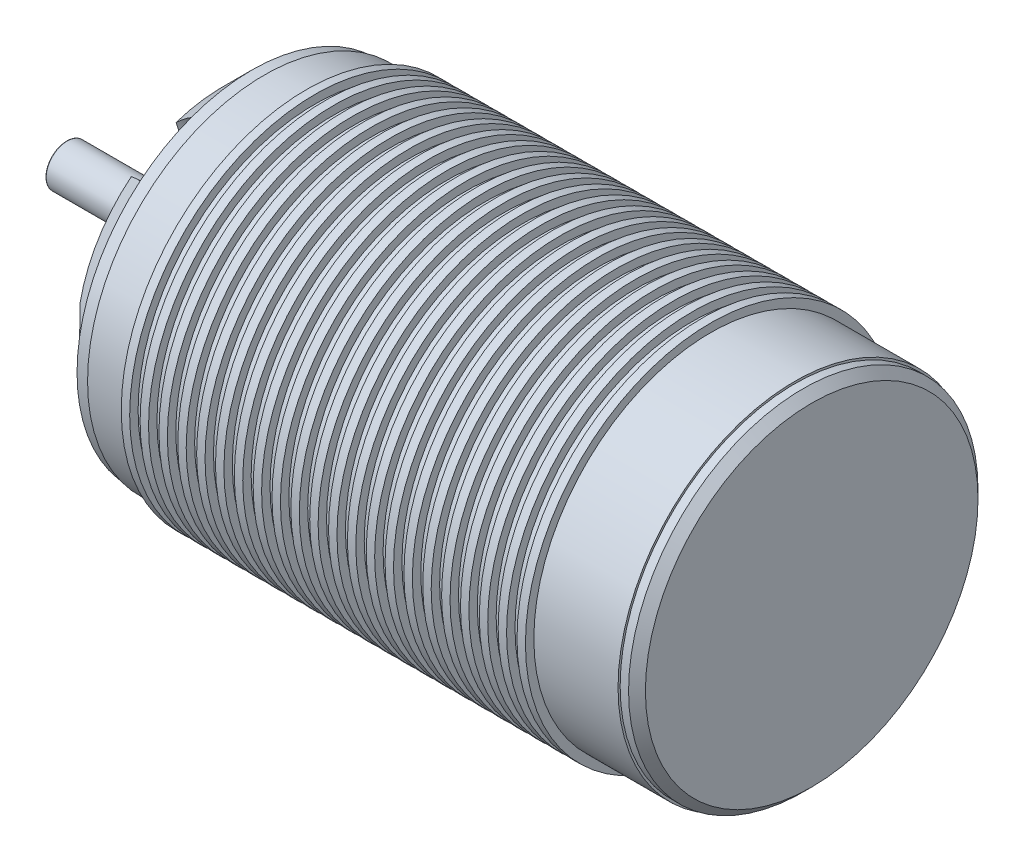
from build123d import *

# Parameters (mm, degrees)
SKETCH3_R                 = 20.75
BOSS_EXTRUDE1_DEPTH       = 2
SKETCH4_R                 = 20.75
BOSS_EXTRUDE2_DEPTH       = 5
CHAMFER1_SIZE             = 3.5
CHAMFER2_SIZE             = 1
SKETCH6_R                 = 4.5
CUT_EXTRUDE1_DEPTH        = 22
SKETCH5_R                 = 2.5
BOSS_EXTRUDE3_DEPTH       = 22
M3X0_5_TAPPED_HOLE1_D     = 2.5
M3X0_5_TAPPED_HOLE1_DEPTH = 7.5
M3X0_5_TAPPED_HOLE1_TIP   = 0.751075774
M4X0_7_TAPPED_HOLE1_D     = 3.3
M4X0_7_TAPPED_HOLE1_DEPTH = 10.1
M4X0_7_TAPPED_HOLE1_TIP   = 0.991420021
FILLET2_R                 = 0.1


with BuildPart() as part:
    # Sketch2 → Revolve1 (revolve)
    with BuildSketch(Plane(origin=(0, 0, 0), x_dir=(1, 0, 0), z_dir=(0, 1, 0))):
        Polygon((-23.261904762, 21), (-23.261904762, 22), (-24.261904762, 22), (-24.261904762, 21), (-25.5, 21), (-25.5, 22), (-26.5, 22), (-26.5, 21), (-31.5, 21), (-31.5, 0), (31.5, 0), (31.5, 21), (21.5, 21), (21.5, 22), (20.5, 22), (20.5, 21), (19.261904762, 21), (19.261904762, 22), (18.261904762, 22), (18.261904762, 21), (17.023809524, 21), (17.023809524, 22), (16.023809524, 22), (16.023809524, 21), (14.785714286, 21), (14.785714286, 22), (13.785714286, 22), (13.785714286, 21), (12.547619048, 21), (12.547619048, 22), (11.547619048, 22), (11.547619048, 21), (10.30952381, 21), (10.30952381, 22), (9.30952381, 22), (9.30952381, 21), (8.071428571, 21), (8.071428571, 22), (7.071428571, 22), (7.071428571, 21), (5.833333333, 21), (5.833333333, 22), (4.833333333, 22), (4.833333333, 21), (3.595238095, 21), (3.595238095, 22), (2.595238095, 22), (2.595238095, 21), (1.357142857, 21), (1.357142857, 22), (0.357142857, 22), (0.357142857, 21), (-0.880952381, 21), (-0.880952381, 22), (-1.880952381, 22), (-1.880952381, 21), (-3.119047619, 21), (-3.119047619, 22), (-4.119047619, 22), (-4.119047619, 21), (-5.357142857, 21), (-5.357142857, 22), (-6.357142857, 22), (-6.357142857, 21), (-7.595238095, 21), (-7.595238095, 22), (-8.595238095, 22), (-8.595238095, 21), (-9.833333333, 21), (-9.833333333, 22), (-10.833333333, 22), (-10.833333333, 21), (-12.071428571, 21), (-12.071428571, 22), (-13.071428571, 22), (-13.071428571, 21), (-14.30952381, 21), (-14.30952381, 22), (-15.30952381, 22), (-15.30952381, 21), (-16.547619048, 21), (-16.547619048, 22), (-17.547619048, 22), (-17.547619048, 21), (-18.785714286, 21), (-18.785714286, 22), (-19.785714286, 22), (-19.785714286, 21), (-21.023809524, 21), (-21.023809524, 22), (-22.023809524, 22), (-22.023809524, 21), align=None)
    revolve(axis=Axis((-31.5, 0, 0), (1, 0, 0)))

    # Sketch3 → Boss-Extrude1 (add)
    with BuildSketch(Plane(origin=(31.5, 0, 0), x_dir=(0, 0, -1), z_dir=(1, 0, 0))):
        Circle(SKETCH3_R)
    extrude(amount=BOSS_EXTRUDE1_DEPTH)

    # Sketch4 → Boss-Extrude2 (add)
    with BuildSketch(Plane.ZY.offset(31.5)):
        Circle(SKETCH4_R)
    extrude(amount=BOSS_EXTRUDE2_DEPTH)

    # Chamfer1
    chamfer1_edges = [part.edges().sort_by_distance(p)[0] for p in [
        (-36.5, 0, -20.75),
    ]]
    chamfer(chamfer1_edges, length=CHAMFER1_SIZE)

    # Chamfer2
    chamfer2_edges = [part.edges().sort_by_distance(p)[0] for p in [
        (33.5, 0, 20.75),
    ]]
    chamfer(chamfer2_edges, length=CHAMFER2_SIZE)

    # Sketch6 → Cut-Extrude1 (cut)
    with BuildSketch(Plane(origin=(-33, 0, 0), x_dir=(0, 0, -1), z_dir=(1, 0, 0))):
        Circle(SKETCH6_R)
        with BuildLine():
            ThreePointArc((-7.195255742, 19.462548518), (-10.375, 17.970027129), (-13.257433568, 15.962548518))
            add(Edge.make_bspline(
                [(-7.195255742, 19.462548518), (-4.303187456, 15.833967112), (-4.457669709, 9.675422315), (-5.519106952, 8.652795829), (-6.90427292, 7.784761365), (-7.324329425, 8.98136581), (-10.367343234, 13.332315093), (-13.257433568, 15.962548518)],
                knots=[0, 0, 0, 0, 0.324704106, 0.382256229, 0.554047337, 0.617969103, 1, 1, 1, 1], degree=3))
        make_face()
        with BuildLine():
            ThreePointArc((-20.45268931, 3.5), (-20.75, 0), (-20.45268931, -3.5))
            add(Edge.make_bspline(
                [(-20.45268931, 3.5), (-15.86421149, 4.190313902), (-10.607996371, 0.977255948), (-10.253094478, -0.453288912), (-10.193937564, -2.086895061), (-11.440255664, -1.852372443), (-16.729795179, -2.312225064), (-20.45268931, -3.5)],
                knots=[0, 0, 0, 0, 0.324704106, 0.382256229, 0.554047337, 0.617969103, 1, 1, 1, 1], degree=3))
        make_face()
        with BuildLine():
            ThreePointArc((-13.257433568, -15.962548518), (-10.375, -17.970027129), (-7.195255742, -19.462548518))
            add(Edge.make_bspline(
                [(-13.257433568, -15.962548518), (-11.561024034, -11.64365321), (-6.150326663, -8.698166367), (-4.733987526, -9.106084741), (-3.289664645, -9.871656426), (-4.11592624, -10.833738252), (-6.362451945, -15.644540157), (-7.195255742, -19.462548518)],
                knots=[0, 0, 0, 0, 0.324704106, 0.382256229, 0.554047337, 0.617969103, 1, 1, 1, 1], degree=3))
        make_face()
        with BuildLine():
            ThreePointArc((7.195255742, -19.462548518), (10.375, -17.970027129), (13.257433568, -15.962548518))
            add(Edge.make_bspline(
                [(7.195255742, -19.462548518), (4.303187456, -15.833967112), (4.457669709, -9.675422315), (5.519106952, -8.652795829), (6.90427292, -7.784761365), (7.324329425, -8.98136581), (10.367343234, -13.332315093), (13.257433568, -15.962548518)],
                knots=[0, 0, 0, 0, 0.324704106, 0.382256229, 0.554047337, 0.617969103, 1, 1, 1, 1], degree=3))
        make_face()
        with BuildLine():
            ThreePointArc((20.45268931, -3.5), (20.75, 0), (20.45268931, 3.5))
            add(Edge.make_bspline(
                [(20.45268931, -3.5), (15.86421149, -4.190313902), (10.607996371, -0.977255948), (10.253094478, 0.453288912), (10.193937564, 2.086895061), (11.440255664, 1.852372443), (16.729795179, 2.312225064), (20.45268931, 3.5)],
                knots=[0, 0, 0, 0, 0.324704106, 0.382256229, 0.554047337, 0.617969103, 1, 1, 1, 1], degree=3))
        make_face()
        with BuildLine():
            ThreePointArc((13.257433568, 15.962548518), (10.375, 17.970027129), (7.195255742, 19.462548518))
            add(Edge.make_bspline(
                [(13.257433568, 15.962548518), (11.561024034, 11.64365321), (6.150326663, 8.698166367), (4.733987526, 9.106084741), (3.289664645, 9.871656426), (4.11592624, 10.833738252), (6.362451945, 15.644540157), (7.195255742, 19.462548518)],
                knots=[0, 0, 0, 0, 0.324704106, 0.382256229, 0.554047337, 0.617969103, 1, 1, 1, 1], degree=3))
        make_face()
    extrude(amount=-CUT_EXTRUDE1_DEPTH, mode=Mode.SUBTRACT)

    # Sketch5 → Boss-Extrude3 (add)
    with BuildSketch(Plane(origin=(-33, 0, 0), x_dir=(0, 0, -1), z_dir=(1, 0, 0))):
        Circle(SKETCH5_R)
    extrude(amount=-BOSS_EXTRUDE3_DEPTH)

    # M3x0.5 Tapped Hole1
    with Locations(Plane.ZY.offset(36.5)):
        with Locations((-10.825317547, 6.25), (-10.825317547, -6.25), (10.825317547, -6.25), (10.825317547, 6.25)):
            Hole(M3X0_5_TAPPED_HOLE1_D / 2, depth=M3X0_5_TAPPED_HOLE1_DEPTH)
            with Locations((0, 0, -(M3X0_5_TAPPED_HOLE1_DEPTH + M3X0_5_TAPPED_HOLE1_TIP / 2))):  # 118° drill point
                Cone(0, M3X0_5_TAPPED_HOLE1_D / 2, M3X0_5_TAPPED_HOLE1_TIP, mode=Mode.SUBTRACT)

    # M4x0.7 Tapped Hole1
    with Locations(Plane.ZY.offset(36.5)):
        with Locations((0, 12.5), (0, -12.5)):
            Hole(M4X0_7_TAPPED_HOLE1_D / 2, depth=M4X0_7_TAPPED_HOLE1_DEPTH)
            with Locations((0, 0, -(M4X0_7_TAPPED_HOLE1_DEPTH + M4X0_7_TAPPED_HOLE1_TIP / 2))):  # 118° drill point
                Cone(0, M4X0_7_TAPPED_HOLE1_D / 2, M4X0_7_TAPPED_HOLE1_TIP, mode=Mode.SUBTRACT)

    # Fillet2
    fillet2_edges = [part.edges().sort_by_distance(p)[0] for p in [
        (-55, 0, 2.5),
    ]]
    fillet(fillet2_edges, radius=FILLET2_R)


solid = part.part
